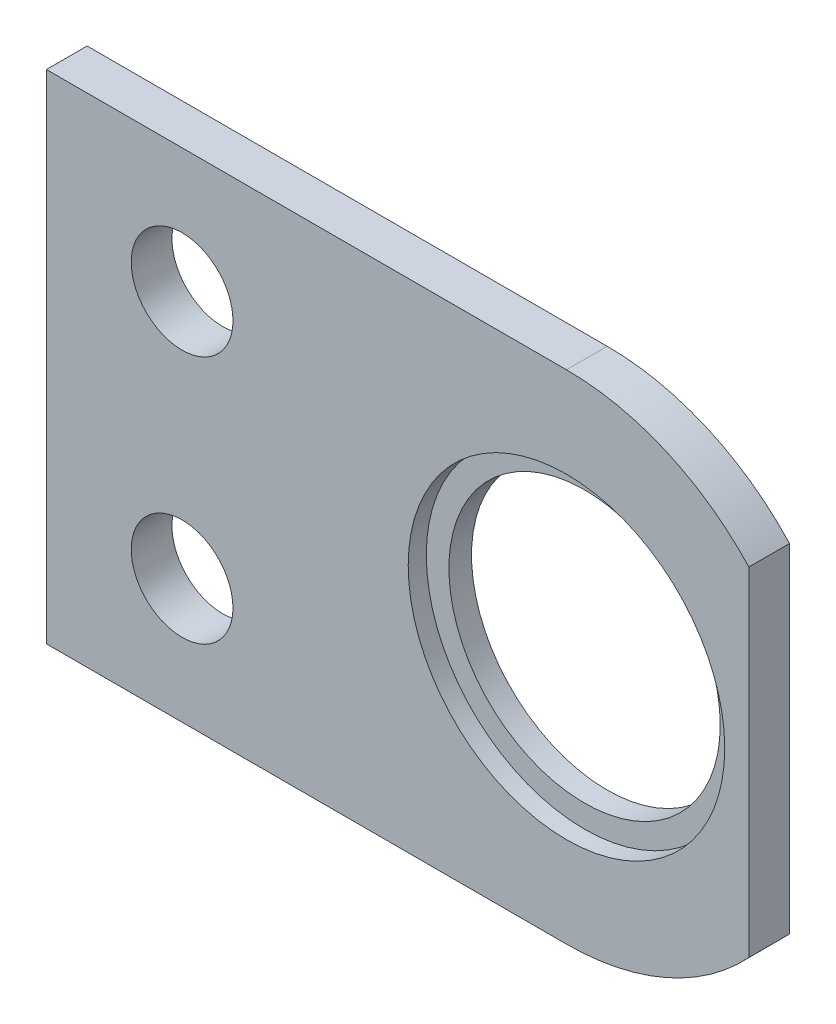
from build123d import *

# Parameters (mm, degrees)
SKETCH_1_R          = 2.25
SKETCH_1_R_2        = 6
EXTRUDE_1_DEPTH     = 1.8
SKETCH_2_R          = 7
CUT_EXTRUDE_1_DEPTH = 0.8


with BuildPart() as part:
    # 草图1 → 凸台-拉伸1 (new body)
    with BuildSketch(Plane.XY):
        with BuildLine():
            Line((0, 7.478796414), (0, -7.478796414))
            ThreePointArc((0, -7.478796414), (-3.665697116, -10.081338219), (-8.066449293, -11))
            Line((-8.066449293, -11), (-31.066449293, -11))
            Line((-31.066449293, -11), (-31.066449293, 11))
            Line((-31.066449293, 11), (-8.066449293, 11))
            ThreePointArc((-8.066449293, 11), (-3.665697116, 10.081338219), (0, 7.478796414))
        make_face()
        with Locations((-25.066449293, 5.5)):
            Circle(SKETCH_1_R, mode=Mode.SUBTRACT)
        with Locations((-25.066449293, -5.5)):
            Circle(SKETCH_1_R, mode=Mode.SUBTRACT)
        with Locations((-8.066449293, 0)):
            Circle(SKETCH_1_R_2, mode=Mode.SUBTRACT)
    extrude(amount=EXTRUDE_1_DEPTH)

    # 草图2 → 切除-拉伸1 (cut)
    with BuildSketch(Plane.XY.offset(1.8)):
        with Locations((-8.066449293, 0)):
            Circle(SKETCH_2_R)
    extrude(amount=-CUT_EXTRUDE_1_DEPTH, mode=Mode.SUBTRACT)


solid = part.part
